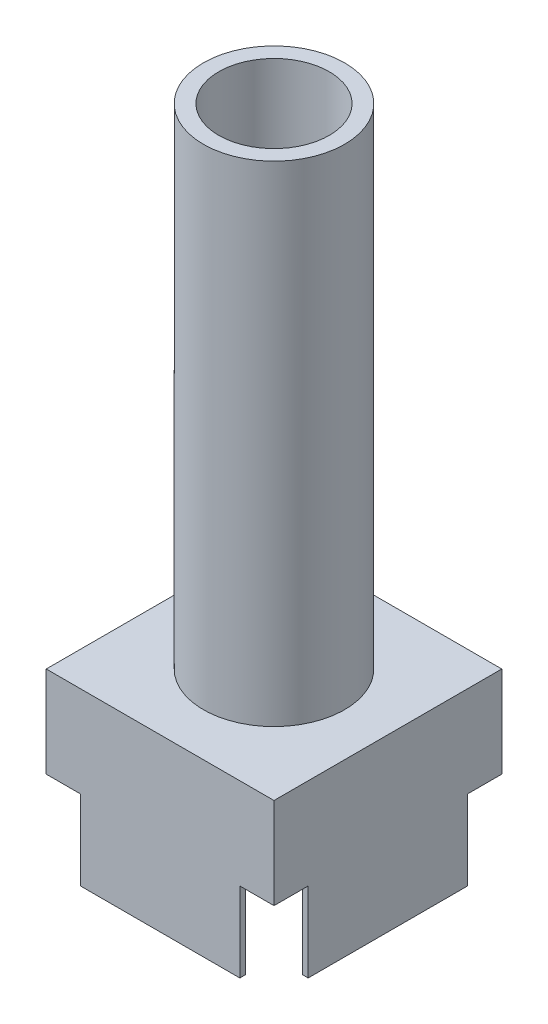
from build123d import *

# Parameters (mm, degrees)
SKETCH_1_W          = 20
SKETCH_1_H          = 20
SKETCH_1_W_2        = 19
SKETCH_1_H_2        = 19
EXTRUDE_1_DEPTH     = 7
SKETCH_3_W          = 20
SKETCH_3_H          = 20
EXTRUDE_2_DEPTH     = 8
SKETCH_4_R          = 6.2
EXTRUDE_3_DEPTH     = 43
SKETCH_5_R          = 4.85
CUT_EXTRUDE_1_DEPTH = 18
SKETCH_6_W          = 3
SKETCH_6_H          = 3
CUT_EXTRUDE_2_DEPTH = 10


with BuildPart() as part:
    # 草圖1 → 填料-伸長1 (new body)
    with BuildSketch(Plane(origin=(0, 0, 0), x_dir=(1, 0, 0), z_dir=(0, 1, 0))):
        with Locations((10, 10)):
            Rectangle(SKETCH_1_W, SKETCH_1_H)
        with Locations((10, 10)):
            Rectangle(SKETCH_1_W_2, SKETCH_1_H_2, mode=Mode.SUBTRACT)
    extrude(amount=EXTRUDE_1_DEPTH)

    # 草圖3 → 填料-伸長2 (add)
    with BuildSketch(Plane(origin=(0, 7, 0), x_dir=(1, 0, 0), z_dir=(0, 1, 0))):
        with Locations((10, 10)):
            Rectangle(SKETCH_3_W, SKETCH_3_H)
    extrude(amount=EXTRUDE_2_DEPTH)

    # 草圖4 → 填料-伸長3 (add)
    with BuildSketch(Plane(origin=(0, 15, 0), x_dir=(1, 0, 0), z_dir=(0, 1, 0))):
        with Locations((10, 10)):
            Circle(SKETCH_4_R)
    extrude(amount=EXTRUDE_3_DEPTH)

    # 草圖5 → 除料-伸長1 (cut)
    with BuildSketch(Plane(origin=(0, 58, 0), x_dir=(1, 0, 0), z_dir=(0, 1, 0))):
        with Locations((10, 10)):
            Circle(SKETCH_5_R)
    extrude(amount=-CUT_EXTRUDE_1_DEPTH, mode=Mode.SUBTRACT)

    # 草圖6 → 除料-伸長2 (cut)
    with BuildSketch(Plane(origin=(0, 7, 0), x_dir=(1, 0, 0), z_dir=(0, 1, 0))):
        with Locations((1.5, 18.5)):
            Rectangle(SKETCH_6_W, SKETCH_6_H)
        with Locations((18.5, 1.5)):
            Rectangle(SKETCH_6_W, SKETCH_6_H)
        with Locations((18.5, 18.5)):
            Rectangle(SKETCH_6_W, SKETCH_6_H)
        with Locations((1.5, 1.5)):
            Rectangle(SKETCH_6_W, SKETCH_6_H)
    extrude(amount=-CUT_EXTRUDE_2_DEPTH, mode=Mode.SUBTRACT)


solid = part.part
